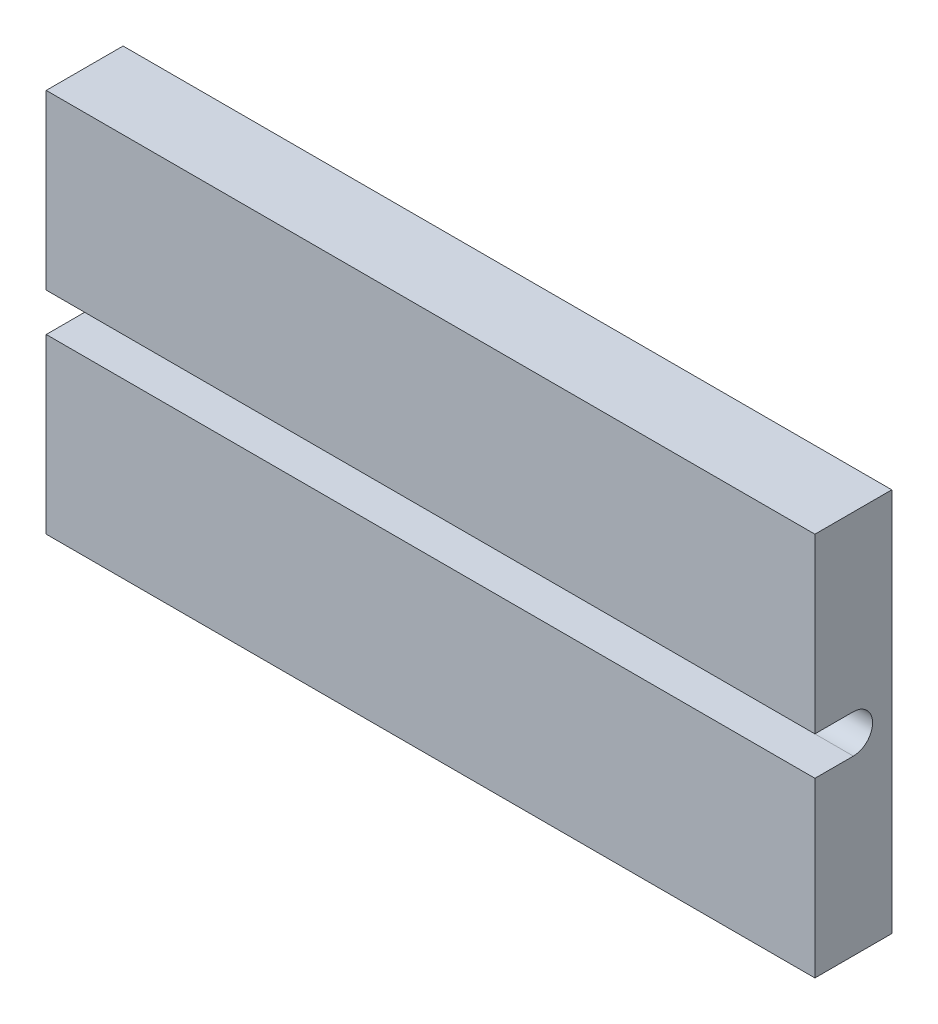
from build123d import *

# Parameters (mm, degrees)
SKETCH_1_W          = 200
SKETCH_1_H          = 100
EXTRUDE_1_DEPTH     = 20
CUT_EXTRUDE_1_DEPTH = 201


with BuildPart() as part:
    # 草图1 → 凸台-拉伸1 (new body)
    with BuildSketch(Plane.XY):
        Rectangle(SKETCH_1_W, SKETCH_1_H)
    extrude(amount=EXTRUDE_1_DEPTH)

    # 草图2 → 切除-拉伸1 (cut, through all)
    with BuildSketch(Plane.ZY.offset(100)):
        with BuildLine():
            Line((10, -5), (20, -5))
            Line((20, -5), (20, 5))
            Line((20, 5), (10, 5))
            ThreePointArc((10, 5), (5, 0), (10, -5))
        make_face()
    extrude(amount=-CUT_EXTRUDE_1_DEPTH, mode=Mode.SUBTRACT)


solid = part.part
